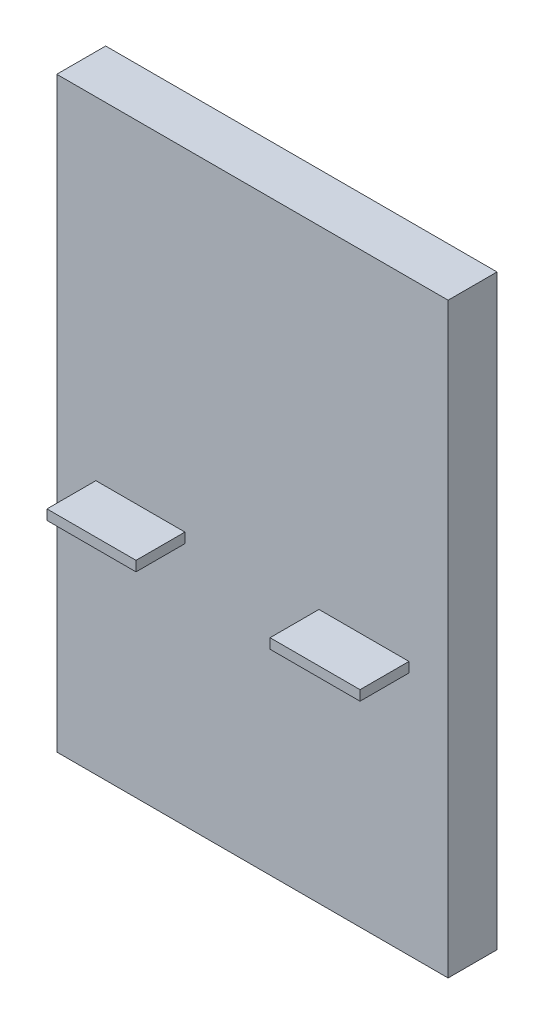
from build123d import *

# Parameters (mm, degrees)
SKETCH1_W           = 2
SKETCH1_H           = 3
BOSS_EXTRUDE1_DEPTH = 0.25
SKETCH2_W           = 0.455012626
SKETCH2_H           = 0.051193531
SKETCH2_W_2         = 0.46
BOSS_EXTRUDE2_DEPTH = 0.25


with BuildPart() as part:
    # Sketch1 → Boss-Extrude1 (new body)
    with BuildSketch(Plane.XY):
        with Locations((0, 1.5)):
            Rectangle(SKETCH1_W, SKETCH1_H)
    extrude(amount=-BOSS_EXTRUDE1_DEPTH)

    # Sketch2 → Boss-Extrude2 (add)
    with BuildSketch(Plane.XY):
        with Locations((-0.572493687, 1.275596766)):
            Rectangle(SKETCH2_W, SKETCH2_H)
        with Locations((0.57, 1.275596766)):
            Rectangle(SKETCH2_W_2, SKETCH2_H)
    extrude(amount=BOSS_EXTRUDE2_DEPTH)


solid = part.part
